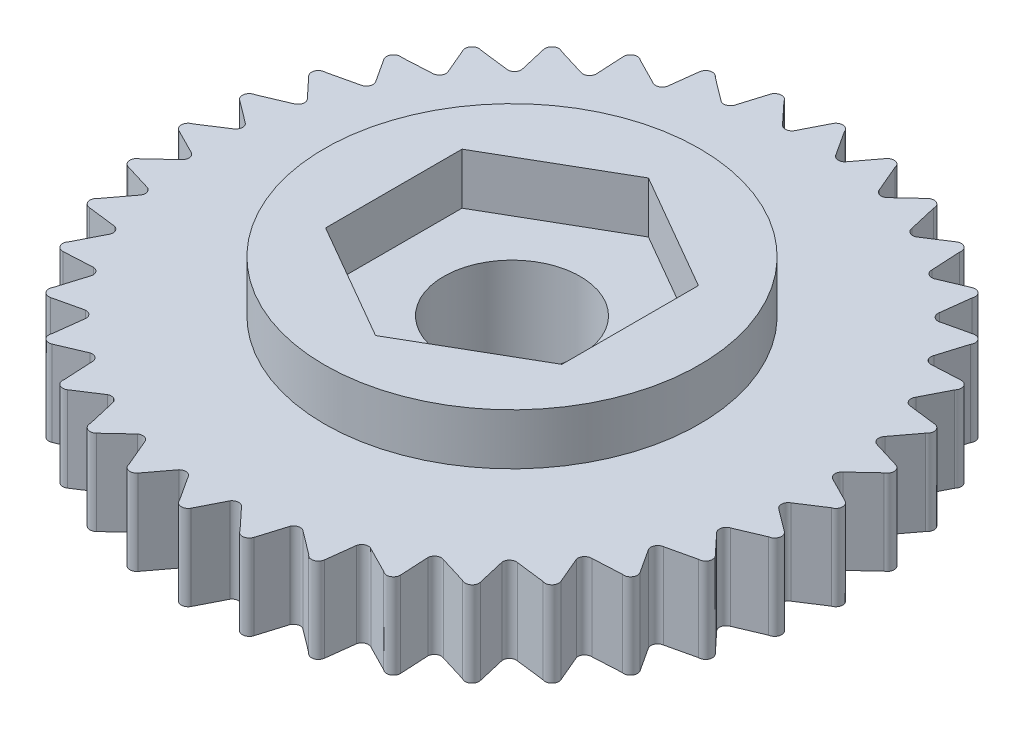
from build123d import *

# Parameters (mm, degrees)
SKETCH1_R           = 5.5
BOSS_EXTRUDE1_DEPTH = 2.5
SKETCH2_R           = 5.5
BOSS_EXTRUDE2_DEPTH = 4
SKETCH3_R           = 2.0025
BOSS_EXTRUDE3_DEPTH = 2.5


with BuildPart() as part:
    # Sketch1 → Boss-Extrude1 (new body)
    with BuildSketch(Plane(origin=(0, 0, 0), x_dir=(1, 0, 0), z_dir=(0, 1, 0))):
        with BuildLine():
            ThreePointArc((0.193177731, 9.558802234), (0.017311703, 9.701185595), (-0.180292753, 9.59093878))
            Line((-0.180292753, 9.59093878), (-0.565794138, 8.833384372))
            ThreePointArc((-0.565794138, 8.833384372), (-0.65340577, 8.762339536), (-0.765525806, 8.75))
            ThreePointArc((-0.765525806, 8.75), (-0.834695638, 8.77621368), (-0.889606614, 8.825775838))
            Line((-0.889606614, 8.825775838), (-1.469625661, 9.447127511))
            ThreePointArc((-1.469625661, 9.447127511), (-1.6675445, 9.556808933), (-1.843002743, 9.413923362))
            Line((-1.843002743, 9.413923362), (-2.091099553, 8.600936294))
            ThreePointArc((-2.091099553, 8.600936294), (-2.16504336, 8.515757188), (-2.273317303, 8.484135678))
            ThreePointArc((-2.273317303, 8.484135678), (-2.345988248, 8.497939898), (-2.408671381, 8.537213904))
            Line((-2.408671381, 8.537213904), (-3.087775221, 9.048406599))
            ThreePointArc((-3.087775221, 9.048406599), (-3.301733208, 9.122053468), (-3.449714026, 8.950870645))
            Line((-3.449714026, 8.950870645), (-3.552867966, 8.107153118))
            ThreePointArc((-3.552867966, 8.107153118), (-3.610897204, 8.010427867), (-3.712035205, 7.960485186))
            ThreePointArc((-3.712035205, 7.960485186), (-3.785999192, 7.961460512), (-3.854549887, 7.989253046))
            Line((-3.854549887, 7.989253046), (-4.612104294, 8.37475443))
            ThreePointArc((-4.612104294, 8.37475443), (-4.835600423, 8.410129024), (-4.951607495, 8.215850253))
            Line((-4.951607495, 8.215850253), (-4.906684283, 7.367038198))
            ThreePointArc((-4.906684283, 7.367038198), (-4.947035763, 7.26170575), (-5.037964795, 7.19495938))
            ThreePointArc((-5.037964795, 7.19495938), (-5.110974467, 7.183076177), (-5.183309846, 7.198542777))
            Line((-5.183309846, 7.198542777), (-5.996296912, 7.446639587))
            ThreePointArc((-5.996296912, 7.446639587), (-6.222540366, 7.442667065), (-6.303048875, 7.231195409))
            Line((-6.303048875, 7.231195409), (-6.111413481, 6.40307955))
            ThreePointArc((-6.111413481, 6.40307955), (-6.132861144, 6.292340377), (-6.210818374, 6.210818374))
            ThreePointArc((-6.210818374, 6.210818374), (-6.280655369, 6.186437708), (-6.354577558, 6.189108428))
            Line((-6.354577558, 6.189108428), (-7.198295082, 6.292262367))
            ThreePointArc((-7.198295082, 6.292262367), (-7.420411568, 6.249063434), (-7.462975305, 6.026824351))
            Line((-7.462975305, 6.026824351), (-7.130450474, 5.24456657))
            ThreePointArc((-7.130450474, 5.24456657), (-7.132342643, 5.131785426), (-7.19495938, 5.037964795))
            ThreePointArc((-7.19495938, 5.037964795), (-7.259501735, 5.001827459), (-7.332764646, 4.991621152))
            Line((-7.332764646, 4.991621152), (-8.181576699, 4.94669794))
            ThreePointArc((-8.181576699, 4.94669794), (-8.392817321, 4.865585172), (-8.396143007, 4.639331286))
            Line((-8.396143007, 4.639331286), (-7.932832337, 3.926700089))
            ThreePointArc((-7.932832337, 3.926700089), (-7.915111519, 3.815303772), (-7.960485186, 3.712035205))
            ThreePointArc((-7.960485186, 3.712035205), (-8.017771815, 3.665239213), (-8.088149391, 3.642465992))
            Line((-8.088149391, 3.642465992), (-8.916265248, 3.450830599))
            ThreePointArc((-8.916265248, 3.450830599), (-9.110211565, 3.334268567), (-9.074198152, 3.110874486))
            Line((-9.074198152, 3.110874486), (-8.494179103, 2.489522812))
            ThreePointArc((-8.494179103, 2.489522812), (-8.457383737, 2.382896044), (-8.484135678, 2.273317303))
            ThreePointArc((-8.484135678, 2.273317303), (-8.532425956, 2.217284529), (-8.597779809, 2.182636347))
            Line((-8.597779809, 2.182636347), (-9.380037589, 1.850111516))
            ThreePointArc((-9.380037589, 1.850111516), (-9.550796642, 1.701641899), (-9.476538378, 1.48789534))
            Line((-9.476538378, 1.48789534), (-8.797434536, 0.976702645))
            ThreePointArc((-8.797434536, 0.976702645), (-8.74268263, 0.878085225), (-8.75, 0.765525806))
            ThreePointArc((-8.75, 0.765525806), (-8.787826651, 0.701958777), (-8.846171039, 0.656488401))
            Line((-8.846171039, 0.656488401), (-9.558802234, 0.193177731))
            ThreePointArc((-9.558802234, 0.193177731), (-9.701185595, 0.017311703), (-9.59093878, -0.180292753))
            Line((-9.59093878, -0.180292753), (-8.833384372, -0.565794138))
            ThreePointArc((-8.833384372, -0.565794138), (-8.762339536, -0.65340577), (-8.75, -0.765525806))
            ThreePointArc((-8.75, -0.765525806), (-8.77621368, -0.834695638), (-8.825775838, -0.889606614))
            Line((-8.825775838, -0.889606614), (-9.447127511, -1.469625661))
            ThreePointArc((-9.447127511, -1.469625661), (-9.556808933, -1.6675445), (-9.413923362, -1.843002743))
            Line((-9.413923362, -1.843002743), (-8.600936294, -2.091099553))
            ThreePointArc((-8.600936294, -2.091099553), (-8.515757188, -2.16504336), (-8.484135678, -2.273317303))
            ThreePointArc((-8.484135678, -2.273317303), (-8.497939898, -2.345988248), (-8.537213904, -2.408671381))
            Line((-8.537213904, -2.408671381), (-9.048406599, -3.087775221))
            ThreePointArc((-9.048406599, -3.087775221), (-9.122053468, -3.301733208), (-8.950870645, -3.449714026))
            Line((-8.950870645, -3.449714026), (-8.107153118, -3.552867966))
            ThreePointArc((-8.107153118, -3.552867966), (-8.010427867, -3.610897204), (-7.960485186, -3.712035205))
            ThreePointArc((-7.960485186, -3.712035205), (-7.961460512, -3.785999192), (-7.989253046, -3.854549887))
            Line((-7.989253046, -3.854549887), (-8.37475443, -4.612104294))
            ThreePointArc((-8.37475443, -4.612104294), (-8.410129024, -4.835600423), (-8.215850253, -4.951607495))
            Line((-8.215850253, -4.951607495), (-7.367038198, -4.906684283))
            ThreePointArc((-7.367038198, -4.906684283), (-7.26170575, -4.947035763), (-7.19495938, -5.037964795))
            ThreePointArc((-7.19495938, -5.037964795), (-7.183076177, -5.110974467), (-7.198542777, -5.183309846))
            Line((-7.198542777, -5.183309846), (-7.446639587, -5.996296912))
            ThreePointArc((-7.446639587, -5.996296912), (-7.442667065, -6.222540366), (-7.231195409, -6.303048875))
            Line((-7.231195409, -6.303048875), (-6.40307955, -6.111413481))
            ThreePointArc((-6.40307955, -6.111413481), (-6.292340377, -6.132861144), (-6.210818374, -6.210818374))
            ThreePointArc((-6.210818374, -6.210818374), (-6.186437708, -6.280655369), (-6.189108428, -6.354577558))
            Line((-6.189108428, -6.354577558), (-6.292262367, -7.198295082))
            ThreePointArc((-6.292262367, -7.198295082), (-6.249063434, -7.420411568), (-6.026824351, -7.462975305))
            Line((-6.026824351, -7.462975305), (-5.24456657, -7.130450474))
            ThreePointArc((-5.24456657, -7.130450474), (-5.131785426, -7.132342643), (-5.037964795, -7.19495938))
            ThreePointArc((-5.037964795, -7.19495938), (-5.001827459, -7.259501735), (-4.991621152, -7.332764646))
            Line((-4.991621152, -7.332764646), (-4.94669794, -8.181576699))
            ThreePointArc((-4.94669794, -8.181576699), (-4.865585172, -8.392817321), (-4.639331286, -8.396143007))
            Line((-4.639331286, -8.396143007), (-3.926700089, -7.932832337))
            ThreePointArc((-3.926700089, -7.932832337), (-3.815303772, -7.915111519), (-3.712035205, -7.960485186))
            ThreePointArc((-3.712035205, -7.960485186), (-3.665239213, -8.017771815), (-3.642465992, -8.088149391))
            Line((-3.642465992, -8.088149391), (-3.450830599, -8.916265248))
            ThreePointArc((-3.450830599, -8.916265248), (-3.334268567, -9.110211565), (-3.110874486, -9.074198152))
            Line((-3.110874486, -9.074198152), (-2.489522812, -8.494179103))
            ThreePointArc((-2.489522812, -8.494179103), (-2.382896044, -8.457383737), (-2.273317303, -8.484135678))
            ThreePointArc((-2.273317303, -8.484135678), (-2.217284529, -8.532425956), (-2.182636347, -8.597779809))
            Line((-2.182636347, -8.597779809), (-1.850111516, -9.380037589))
            ThreePointArc((-1.850111516, -9.380037589), (-1.701641899, -9.550796642), (-1.48789534, -9.476538378))
            Line((-1.48789534, -9.476538378), (-0.976702645, -8.797434536))
            ThreePointArc((-0.976702645, -8.797434536), (-0.878085225, -8.74268263), (-0.765525806, -8.75))
            ThreePointArc((-0.765525806, -8.75), (-0.701958777, -8.787826651), (-0.656488401, -8.846171039))
            Line((-0.656488401, -8.846171039), (-0.193177731, -9.558802234))
            ThreePointArc((-0.193177731, -9.558802234), (-0.017311703, -9.701185595), (0.180292753, -9.59093878))
            Line((0.180292753, -9.59093878), (0.565794138, -8.833384372))
            ThreePointArc((0.565794138, -8.833384372), (0.65340577, -8.762339536), (0.765525806, -8.75))
            ThreePointArc((0.765525806, -8.75), (0.834695638, -8.77621368), (0.889606614, -8.825775838))
            Line((0.889606614, -8.825775838), (1.469625661, -9.447127511))
            ThreePointArc((1.469625661, -9.447127511), (1.6675445, -9.556808933), (1.843002743, -9.413923362))
            Line((1.843002743, -9.413923362), (2.091099553, -8.600936294))
            ThreePointArc((2.091099553, -8.600936294), (2.16504336, -8.515757188), (2.273317303, -8.484135678))
            ThreePointArc((2.273317303, -8.484135678), (2.345988248, -8.497939898), (2.408671381, -8.537213904))
            Line((2.408671381, -8.537213904), (3.087775221, -9.048406599))
            ThreePointArc((3.087775221, -9.048406599), (3.301733208, -9.122053468), (3.449714026, -8.950870645))
            Line((3.449714026, -8.950870645), (3.552867966, -8.107153118))
            ThreePointArc((3.552867966, -8.107153118), (3.610897204, -8.010427867), (3.712035205, -7.960485186))
            ThreePointArc((3.712035205, -7.960485186), (3.785999192, -7.961460512), (3.854549887, -7.989253046))
            Line((3.854549887, -7.989253046), (4.612104294, -8.37475443))
            ThreePointArc((4.612104294, -8.37475443), (4.835600423, -8.410129024), (4.951607495, -8.215850253))
            Line((4.951607495, -8.215850253), (4.906684283, -7.367038198))
            ThreePointArc((4.906684283, -7.367038198), (4.947035763, -7.26170575), (5.037964795, -7.19495938))
            ThreePointArc((5.037964795, -7.19495938), (5.110974467, -7.183076177), (5.183309846, -7.198542777))
            Line((5.183309846, -7.198542777), (5.996296912, -7.446639587))
            ThreePointArc((5.996296912, -7.446639587), (6.222540366, -7.442667065), (6.303048875, -7.231195409))
            Line((6.303048875, -7.231195409), (6.111413481, -6.40307955))
            ThreePointArc((6.111413481, -6.40307955), (6.132861144, -6.292340377), (6.210818374, -6.210818374))
            ThreePointArc((6.210818374, -6.210818374), (6.280655369, -6.186437708), (6.354577558, -6.189108428))
            Line((6.354577558, -6.189108428), (7.198295082, -6.292262367))
            ThreePointArc((7.198295082, -6.292262367), (7.420411568, -6.249063434), (7.462975305, -6.026824351))
            Line((7.462975305, -6.026824351), (7.130450474, -5.24456657))
            ThreePointArc((7.130450474, -5.24456657), (7.132342643, -5.131785426), (7.19495938, -5.037964795))
            ThreePointArc((7.19495938, -5.037964795), (7.259501735, -5.001827459), (7.332764646, -4.991621152))
            Line((7.332764646, -4.991621152), (8.181576699, -4.94669794))
            ThreePointArc((8.181576699, -4.94669794), (8.392817321, -4.865585172), (8.396143007, -4.639331286))
            Line((8.396143007, -4.639331286), (7.932832337, -3.926700089))
            ThreePointArc((7.932832337, -3.926700089), (7.915111519, -3.815303772), (7.960485186, -3.712035205))
            ThreePointArc((7.960485186, -3.712035205), (8.017771815, -3.665239213), (8.088149391, -3.642465992))
            Line((8.088149391, -3.642465992), (8.916265248, -3.450830599))
            ThreePointArc((8.916265248, -3.450830599), (9.110211565, -3.334268567), (9.074198152, -3.110874486))
            Line((9.074198152, -3.110874486), (8.494179103, -2.489522812))
            ThreePointArc((8.494179103, -2.489522812), (8.457383737, -2.382896044), (8.484135678, -2.273317303))
            ThreePointArc((8.484135678, -2.273317303), (8.532425956, -2.217284529), (8.597779809, -2.182636347))
            Line((8.597779809, -2.182636347), (9.380037589, -1.850111516))
            ThreePointArc((9.380037589, -1.850111516), (9.550796642, -1.701641899), (9.476538378, -1.48789534))
            Line((9.476538378, -1.48789534), (8.797434536, -0.976702645))
            ThreePointArc((8.797434536, -0.976702645), (8.74268263, -0.878085225), (8.75, -0.765525806))
            ThreePointArc((8.75, -0.765525806), (8.787826651, -0.701958777), (8.846171039, -0.656488401))
            Line((8.846171039, -0.656488401), (9.558802234, -0.193177731))
            ThreePointArc((9.558802234, -0.193177731), (9.701185595, -0.017311703), (9.59093878, 0.180292753))
            Line((9.59093878, 0.180292753), (8.833384372, 0.565794138))
            ThreePointArc((8.833384372, 0.565794138), (8.762339536, 0.65340577), (8.75, 0.765525806))
            ThreePointArc((8.75, 0.765525806), (8.77621368, 0.834695638), (8.825775838, 0.889606614))
            Line((8.825775838, 0.889606614), (9.447127511, 1.469625661))
            ThreePointArc((9.447127511, 1.469625661), (9.556808933, 1.6675445), (9.413923362, 1.843002743))
            Line((9.413923362, 1.843002743), (8.600936294, 2.091099553))
            ThreePointArc((8.600936294, 2.091099553), (8.515757188, 2.16504336), (8.484135678, 2.273317303))
            ThreePointArc((8.484135678, 2.273317303), (8.497939898, 2.345988248), (8.537213904, 2.408671381))
            Line((8.537213904, 2.408671381), (9.048406599, 3.087775221))
            ThreePointArc((9.048406599, 3.087775221), (9.122053468, 3.301733208), (8.950870645, 3.449714026))
            Line((8.950870645, 3.449714026), (8.107153118, 3.552867966))
            ThreePointArc((8.107153118, 3.552867966), (8.010427867, 3.610897204), (7.960485186, 3.712035205))
            ThreePointArc((7.960485186, 3.712035205), (7.961460512, 3.785999192), (7.989253046, 3.854549887))
            Line((7.989253046, 3.854549887), (8.37475443, 4.612104294))
            ThreePointArc((8.37475443, 4.612104294), (8.410129024, 4.835600423), (8.215850253, 4.951607495))
            Line((8.215850253, 4.951607495), (7.367038198, 4.906684283))
            ThreePointArc((7.367038198, 4.906684283), (7.26170575, 4.947035763), (7.19495938, 5.037964795))
            ThreePointArc((7.19495938, 5.037964795), (7.183076177, 5.110974467), (7.198542777, 5.183309846))
            Line((7.198542777, 5.183309846), (7.446639587, 5.996296912))
            ThreePointArc((7.446639587, 5.996296912), (7.442667065, 6.222540366), (7.231195409, 6.303048875))
            Line((7.231195409, 6.303048875), (6.40307955, 6.111413481))
            ThreePointArc((6.40307955, 6.111413481), (6.292340377, 6.132861144), (6.210818374, 6.210818374))
            ThreePointArc((6.210818374, 6.210818374), (6.186437708, 6.280655369), (6.189108428, 6.354577558))
            Line((6.189108428, 6.354577558), (6.292262367, 7.198295082))
            ThreePointArc((6.292262367, 7.198295082), (6.249063434, 7.420411568), (6.026824351, 7.462975305))
            Line((6.026824351, 7.462975305), (5.24456657, 7.130450474))
            ThreePointArc((5.24456657, 7.130450474), (5.131785426, 7.132342643), (5.037964795, 7.19495938))
            ThreePointArc((5.037964795, 7.19495938), (5.001827459, 7.259501735), (4.991621152, 7.332764646))
            Line((4.991621152, 7.332764646), (4.94669794, 8.181576699))
            ThreePointArc((4.94669794, 8.181576699), (4.865585172, 8.392817321), (4.639331286, 8.396143007))
            Line((4.639331286, 8.396143007), (3.926700089, 7.932832337))
            ThreePointArc((3.926700089, 7.932832337), (3.815303772, 7.915111519), (3.712035205, 7.960485186))
            ThreePointArc((3.712035205, 7.960485186), (3.665239213, 8.017771815), (3.642465992, 8.088149391))
            Line((3.642465992, 8.088149391), (3.450830599, 8.916265248))
            ThreePointArc((3.450830599, 8.916265248), (3.334268567, 9.110211565), (3.110874486, 9.074198152))
            Line((3.110874486, 9.074198152), (2.489522812, 8.494179103))
            ThreePointArc((2.489522812, 8.494179103), (2.382896044, 8.457383737), (2.273317303, 8.484135678))
            ThreePointArc((2.273317303, 8.484135678), (2.217284529, 8.532425956), (2.182636347, 8.597779809))
            Line((2.182636347, 8.597779809), (1.850111516, 9.380037589))
            ThreePointArc((1.850111516, 9.380037589), (1.701641899, 9.550796642), (1.48789534, 9.476538378))
            Line((1.48789534, 9.476538378), (0.976702645, 8.797434536))
            ThreePointArc((0.976702645, 8.797434536), (0.878085225, 8.74268263), (0.765525806, 8.75))
            ThreePointArc((0.765525806, 8.75), (0.701958777, 8.787826651), (0.656488401, 8.846171039))
            Line((0.656488401, 8.846171039), (0.193177731, 9.558802234))
        make_face()
        Circle(SKETCH1_R, mode=Mode.SUBTRACT)
    extrude(amount=BOSS_EXTRUDE1_DEPTH)

    # Sketch2 → Boss-Extrude2 (add)
    with BuildSketch(Plane(origin=(0, 0, 0), x_dir=(1, 0, 0), z_dir=(0, 1, 0))):
        Circle(SKETCH2_R)
        Polygon((0, 4.0025), (-3.466266679, 2.00125), (-3.466266679, -2.00125), (0, -4.0025), (3.466266679, -2.00125), (3.466266679, 2.00125), align=None, mode=Mode.SUBTRACT)
    extrude(amount=BOSS_EXTRUDE2_DEPTH)

    # Sketch3 → Boss-Extrude3 (add)
    with BuildSketch(Plane(origin=(0, 0, 0), x_dir=(1, 0, 0), z_dir=(0, 1, 0))):
        Polygon((0, 4.0025), (-3.466266679, 2.00125), (-3.466266679, -2.00125), (0, -4.0025), (3.466266679, -2.00125), (3.466266679, 2.00125), align=None)
        Circle(SKETCH3_R, mode=Mode.SUBTRACT)
    extrude(amount=BOSS_EXTRUDE3_DEPTH)


solid = part.part
